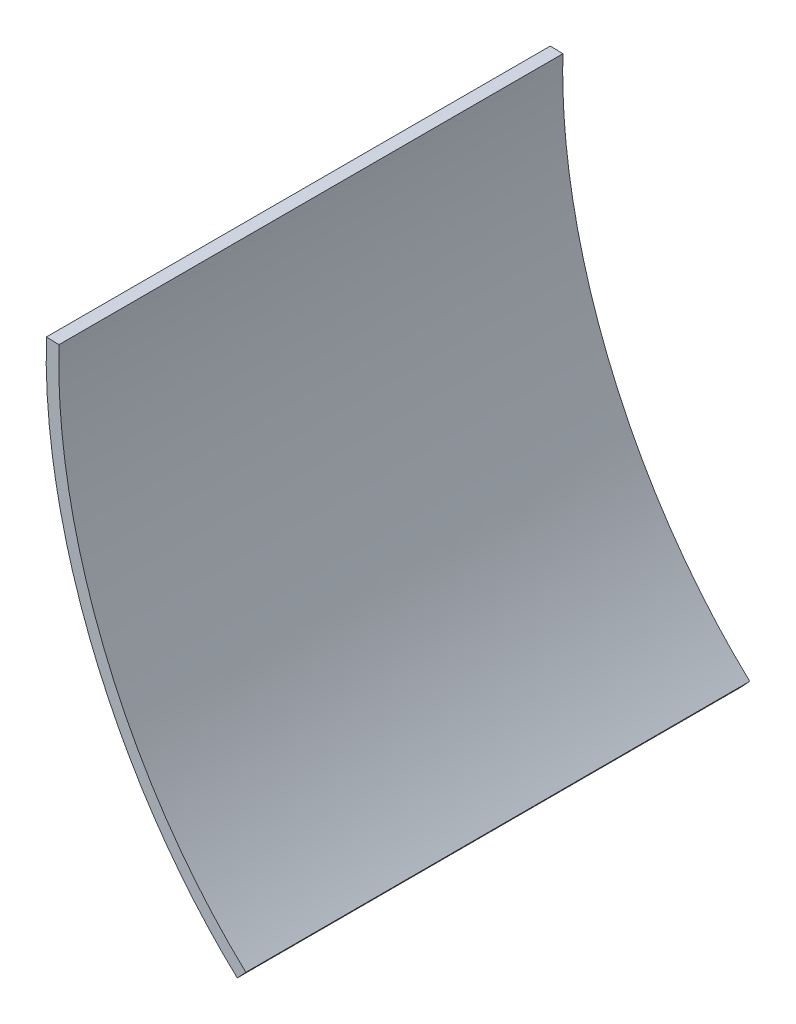
from build123d import *

# Parameters (mm, degrees)
BOSS_EXTRUDE1_DEPTH = 101.6


with BuildPart() as part:
    # Sketch1 → Boss-Extrude1 (new body)
    with BuildSketch(Plane.XY):
        with BuildLine():
            Line((60.066875563, -39.515937039), (62.605766474, -39.590989952))
            add(Edge.make_bspline(
                [(100.277127399, -130.340132391), (76.099968015, -107.898756151), (61.630828527, -72.571203637), (62.605766474, -39.590989952)],
                knots=[0, 0, 0, 0, 1, 1, 1, 1], degree=3))
            Line((100.277127399, -130.340132391), (98.549147287, -132.201767352))
            add(Edge.make_bspline(
                [(98.549147287, -132.201767352), (95.437130018, -129.313175302), (89.581033369, -123.176238056), (81.771611434, -112.898614813), (75.048825569, -101.775636026), (69.461616789, -89.97189143), (65.078002604, -77.666809047), (61.963470194, -65.033167265), (60.48295532, -54.380238589), (60.003375773, -45.862596658), (60.004292397, -41.633001174), (60.066875563, -39.515937039)],
                knots=[0, 0, 0, 0, 0.125, 0.25, 0.375, 0.5, 0.625, 0.75, 0.875, 0.9375, 1, 1, 1, 1], degree=3))
        make_face()
    extrude(amount=-BOSS_EXTRUDE1_DEPTH)


solid = part.part
